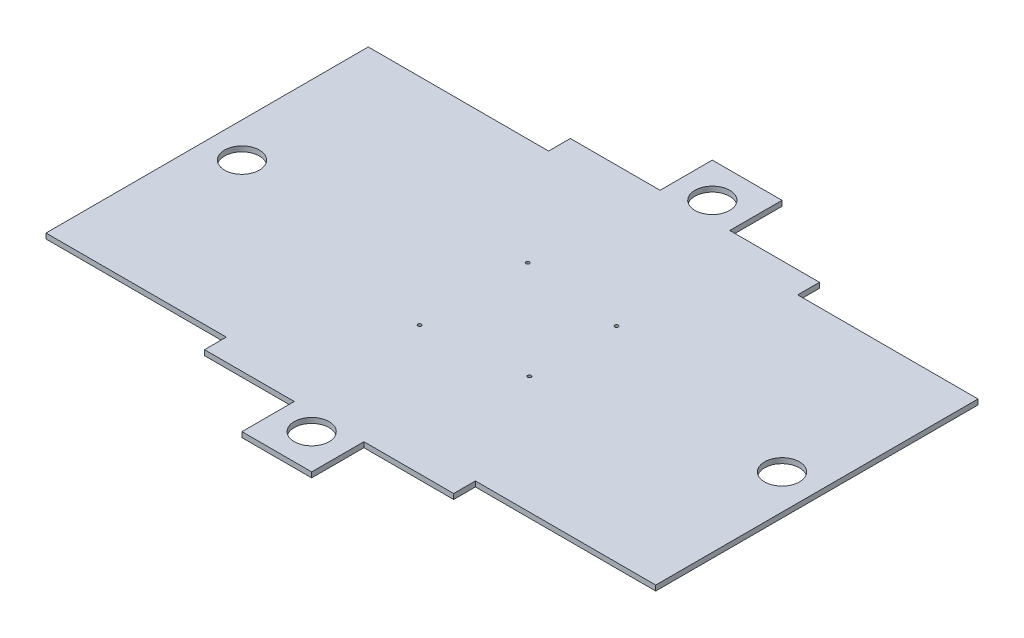
from build123d import *

# Parameters (mm, degrees)
SKETCH1_R           = 1
SKETCH1_R_2         = 10
BOSS_EXTRUDE1_DEPTH = 3


with BuildPart() as part:
    # Sketch1 → Boss-Extrude1 (new body)
    with BuildSketch(Plane(origin=(0, 0, 0), x_dir=(1, 0, 0), z_dir=(0, 1, 0))):
        Polygon((-111.790938792, 69.703810947), (-111.790938792, 82.203810947), (-60.290938792, 82.203810947), (-60.290938792, 112.203810947), (-20.290938792, 112.203810947), (-20.290938792, 82.203810947), (31.209061208, 82.203810947), (31.209061208, 69.703810947), (134.709061208, 69.703810947), (134.709061208, -115.296189053), (31.209061208, -115.296189053), (31.209061208, -127.796189053), (-20.290938792, -127.796189053), (-20.290938792, -157.796189053), (-60.290938792, -157.796189053), (-60.290938792, -127.796189053), (-111.790938792, -127.796189053), (-111.790938792, -115.296189053), (-215.290938792, -115.296189053), (-215.290938792, 69.703810947), align=None)
        with Locations((-5.290938792, -47.796189053)):
            Circle(SKETCH1_R, mode=Mode.SUBTRACT)
        with Locations((-5.290938792, 2.203810947)):
            Circle(SKETCH1_R, mode=Mode.SUBTRACT)
        with Locations((-62.290938792, -53.796189053)):
            Circle(SKETCH1_R, mode=Mode.SUBTRACT)
        with Locations((-62.290938792, 8.203810947)):
            Circle(SKETCH1_R, mode=Mode.SUBTRACT)
        with Locations((-40.290938792, 92.203810947)):
            Circle(SKETCH1_R_2, mode=Mode.SUBTRACT)
        with Locations((-40.290938792, -137.796189053)):
            Circle(SKETCH1_R_2, mode=Mode.SUBTRACT)
        with Locations((114.709061208, -22.796189053)):
            Circle(SKETCH1_R_2, mode=Mode.SUBTRACT)
        with Locations((-195.290938792, -22.796189053)):
            Circle(SKETCH1_R_2, mode=Mode.SUBTRACT)
    extrude(amount=BOSS_EXTRUDE1_DEPTH)


solid = part.part
